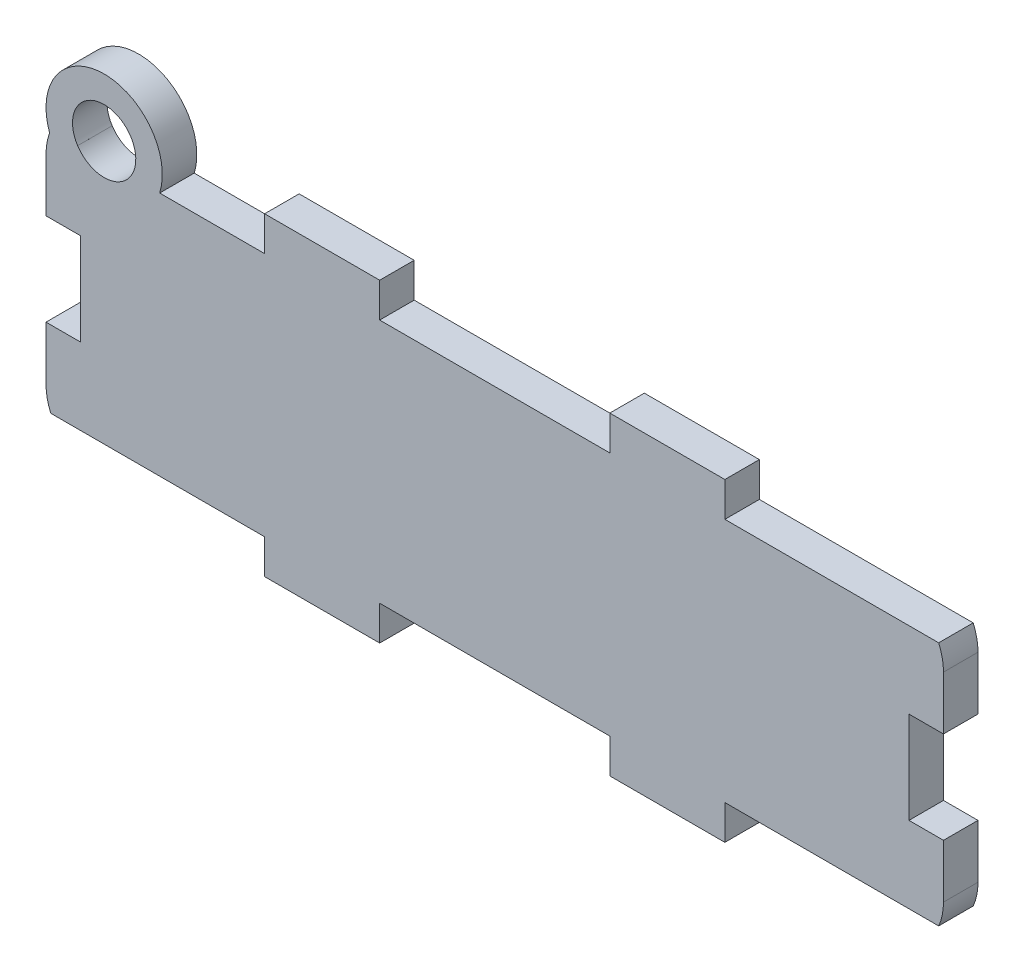
from build123d import *

# Parameters (mm, degrees)
BOSS_EXTRUDE1_DEPTH = 3
SKETCH3_R           = 5.053902861
SKETCH3_R_2         = 2.75
BOSS_EXTRUDE3_DEPTH = 3
CUT_EXTRUDE1_DEPTH  = 3
SKETCH5_W           = 3
SKETCH5_H           = 8
CUT_EXTRUDE2_DEPTH  = 3


with BuildPart() as part:
    # Sketch1 → Boss-Extrude1 (new body)
    with BuildSketch(Plane.XY):
        with BuildLine():
            Line((-7, -3), (3, -3))
            Line((3, -3), (3, 0))
            Line((3, 0), (23, 0))
            Line((23, 0), (23, -3))
            Line((23, -3), (33, -3))
            Line((33, -3), (33, 0))
            Line((33, 0), (51.582575695, 0))
            ThreePointArc((51.582575695, 0), (51.894531565, 0.978451782), (52, 2))
            Line((52, 2), (52, 19.311841589))
            ThreePointArc((52, 19.311841589), (51.894531565, 20.333389808), (51.582575695, 21.311841589))
            Line((51.582575695, 21.311841589), (33, 21.311841589))
            Line((33, 21.311841589), (33, 24.311841589))
            Line((33, 24.311841589), (23, 24.311841589))
            Line((23, 24.311841589), (23, 21.311841589))
            Line((23, 21.311841589), (3, 21.311841589))
            Line((3, 21.311841589), (3, 24.311841589))
            Line((3, 24.311841589), (-7, 24.311841589))
            Line((-7, 24.311841589), (-7, 21.311841589))
            Line((-7, 21.311841589), (-25.582575695, 21.311841589))
            ThreePointArc((-25.582575695, 21.311841589), (-25.894531565, 20.333389808), (-26, 19.311841589))
            Line((-26, 19.311841589), (-26, 2))
            ThreePointArc((-26, 2), (-25.894531565, 0.978451782), (-25.582575695, 0))
            Line((-25.582575695, 0), (-7, 0))
            Line((-7, 0), (-7, -3))
        make_face()
    extrude(amount=BOSS_EXTRUDE1_DEPTH)

    # Sketch3 → Boss-Extrude3 (add)
    with BuildSketch(Plane(origin=(0, 0, 0), x_dir=(-1, 0, 0), z_dir=(0, 0, -1))):
        with Locations((20.946097139, 22.811841589)):
            Circle(SKETCH3_R)
        with Locations((20.946097139, 22.811841589)):
            Circle(SKETCH3_R_2, mode=Mode.SUBTRACT)
    extrude(amount=-BOSS_EXTRUDE3_DEPTH)

    # Sketch4 → Cut-Extrude1 (cut)
    with BuildSketch(Plane(origin=(0, 0, 0), x_dir=(-1, 0, 0), z_dir=(0, 0, -1))):
        with BuildLine():
            Line((23.250708633, 21.311841589), (18.641485645, 21.311841589))
            ThreePointArc((18.641485645, 21.311841589), (20.946097139, 20.062071756), (23.250708633, 21.311841589))
        make_face()
    extrude(amount=-CUT_EXTRUDE1_DEPTH, mode=Mode.SUBTRACT)

    # Sketch5 → Cut-Extrude2 (cut)
    with BuildSketch(Plane(origin=(0, 0, 0), x_dir=(-1, 0, 0), z_dir=(0, 0, -1))):
        with Locations((24.5, 10.655920795)):
            Rectangle(SKETCH5_W, SKETCH5_H)
        with Locations((-50.5, 10.655920795)):
            Rectangle(SKETCH5_W, SKETCH5_H)
    extrude(amount=-CUT_EXTRUDE2_DEPTH, mode=Mode.SUBTRACT)


solid = part.part
